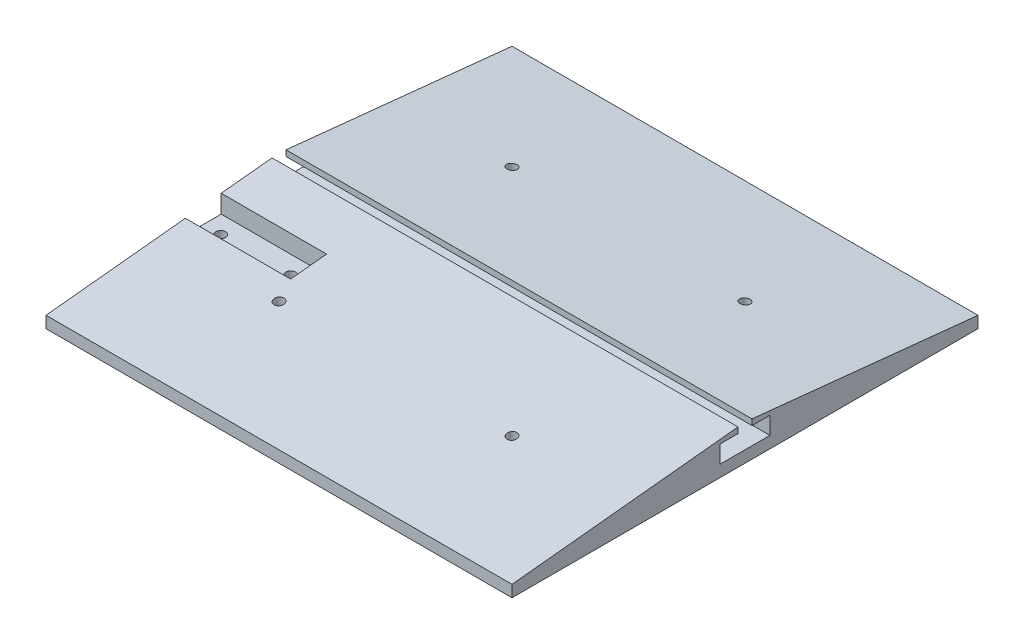
from build123d import *

# Parameters (mm, degrees)
SKETCH1_W           = 200
SKETCH1_H           = 200
BOSS_EXTRUDE1_DEPTH = 5
BOSS_EXTRUDE2_DEPTH = 200
CUT_EXTRUDE9_START  = -200
SKETCH13_W          = 21.4
SKETCH13_H          = 7.5
CUT_EXTRUDE9_DEPTH  = 200
CUT_EXTRUDE14_START = -2
CUT_EXTRUDE14_DEPTH = 3.6
SKETCH17_R          = 2.1
CUT_EXTRUDE15_DEPTH = 16
SKETCH19_W          = 15.4
SKETCH19_H          = 7.75257732
CUT_EXTRUDE16_DEPTH = 45.2
SKETCH20_R          = 2.1
CUT_EXTRUDE17_DEPTH = 45


with BuildPart() as part:
    # Sketch1 → Boss-Extrude1 (new body)
    with BuildSketch(Plane(origin=(0, 0, 0), x_dir=(1, 0, 0), z_dir=(0, 1, 0))):
        Rectangle(SKETCH1_W, SKETCH1_H)
    extrude(amount=BOSS_EXTRUDE1_DEPTH)

    # Sketch9 → Boss-Extrude2 (add)
    with BuildSketch(Plane(origin=(100, 0, 0), x_dir=(0, 0, -1), z_dir=(1, 0, 0))):
        Polygon((-100, 5), (-3, 15), (-3, 5), align=None)
        Polygon((3, 5), (100, 5), (3, 15), align=None)
    extrude(amount=-BOSS_EXTRUDE2_DEPTH)

    # Sketch13 → Cut-Extrude9 (cut)
    with BuildSketch(Plane.ZY.offset(100).offset(CUT_EXTRUDE9_START)):
        with Locations((0, 8.75)):
            Rectangle(SKETCH13_W, SKETCH13_H)
    extrude(amount=CUT_EXTRUDE9_DEPTH, mode=Mode.SUBTRACT)

    # Sketch18 → Cut-Extrude14 (cut)
    with BuildSketch(Plane.XZ.offset(CUT_EXTRUDE14_START)):
        Polygon((-52.136195996, 46.3), (-47.863804004, 46.3), (-45.727608008, 50), (-47.863804004, 53.7), (-52.136195996, 53.7), (-54.272391992, 53.7), (-54.272391992, 46.3), align=None)
        Polygon((47.863804004, 46.3), (52.136195996, 46.3), (54.272391992, 50), (52.136195996, 53.7), (47.863804004, 53.7), (45.727608008, 53.7), (45.727608008, 46.3), align=None)
        Polygon((47.863804004, -53.7), (52.136195996, -53.7), (54.272391992, -50), (52.136195996, -46.3), (47.863804004, -46.3), (45.727608008, -46.3), (45.727608008, -53.7), align=None)
        Polygon((-52.136195996, -53.7), (-47.863804004, -53.7), (-45.727608008, -50), (-47.863804004, -46.3), (-52.136195996, -46.3), (-54.272391992, -46.3), (-54.272391992, -53.7), align=None)
    extrude(amount=-CUT_EXTRUDE14_DEPTH, mode=Mode.SUBTRACT)

    # Sketch17 → Cut-Extrude15 (cut, through all)
    with BuildSketch(Plane.XZ):
        with Locations((-50, 50)):
            Circle(SKETCH17_R)
        with Locations((50, 50)):
            Circle(SKETCH17_R)
        with Locations((50, -50)):
            Circle(SKETCH17_R)
        with Locations((-50, -50)):
            Circle(SKETCH17_R)
    extrude(amount=-CUT_EXTRUDE15_DEPTH, mode=Mode.SUBTRACT)

    # Sketch19 → Cut-Extrude16 (cut)
    with BuildSketch(Plane.ZY.offset(100)):
        with Locations((32.5, 8.87628866)):
            Rectangle(SKETCH19_W, SKETCH19_H)
    extrude(amount=-CUT_EXTRUDE16_DEPTH, mode=Mode.SUBTRACT)

    # Sketch20 → Cut-Extrude17 (cut)
    with BuildSketch(Plane(origin=(0, 5, 0), x_dir=(1, 0, 0), z_dir=(0, 1, 0))):
        with Locations((-92.5, -32.5)):
            Circle(SKETCH20_R)
        with Locations((-62.5, -32.5)):
            Circle(SKETCH20_R)
    extrude(amount=-CUT_EXTRUDE17_DEPTH, mode=Mode.SUBTRACT)


solid = part.part
